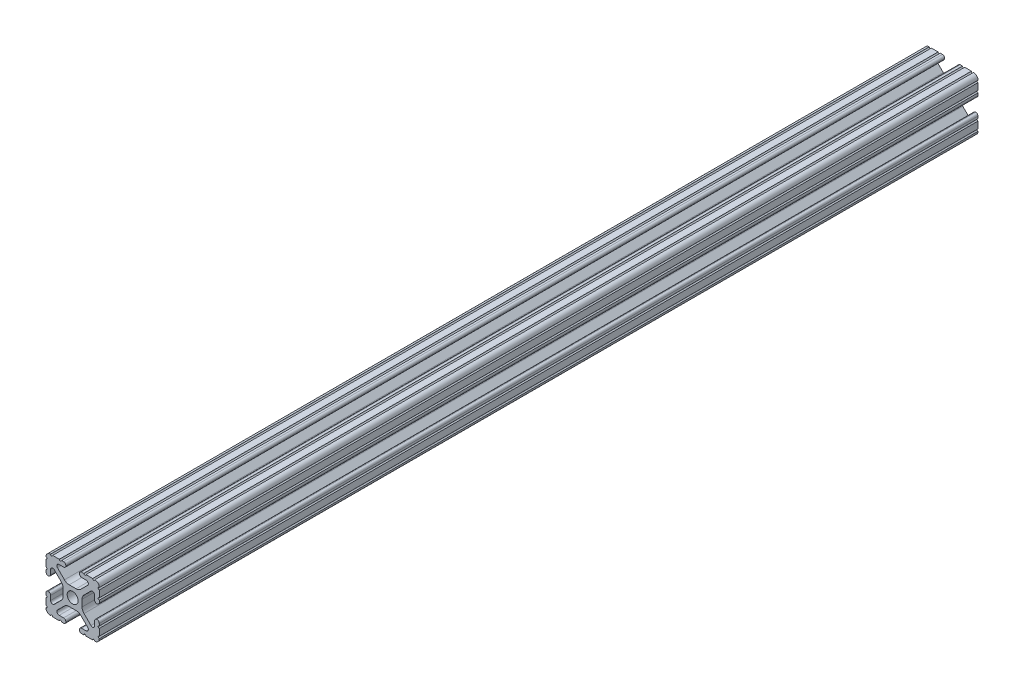
from build123d import *

# Parameters (mm, degrees)
SKETCH1_R           = 2.6035
BOSS_EXTRUDE1_DEPTH = 209.55


with BuildPart() as part:
    # Sketch1 → Boss-Extrude1 (new body, symmetric)
    with BuildSketch(Plane.XY):
        with BuildLine():
            Line((-7.179650497, -8.645192506), (-3.952270251, -5.423690499))
            ThreePointArc((-3.952270251, -5.423690499), (-2.922936451, -4.736929036), (-1.709253557, -4.4958))
            Line((-1.709253557, -4.4958), (1.709253557, -4.4958))
            ThreePointArc((1.709253557, -4.4958), (2.922936451, -4.736929036), (3.952270251, -5.423690499))
            Line((3.952270251, -5.423690499), (7.179650497, -8.645192506))
            ThreePointArc((7.179650497, -8.645192506), (7.41473083, -9.822813117), (6.416408329, -10.4902))
            Line((6.416408329, -10.4902), (4.287512407, -10.4902))
            ThreePointArc((4.287512407, -10.4902), (3.54574862, -10.79744862), (3.2385, -11.539212407))
            Line((3.2385, -11.539212407), (3.2385, -11.650987593))
            ThreePointArc((3.2385, -11.650987593), (3.54574862, -12.39275138), (4.287512407, -12.7))
            Line((4.287512407, -12.7), (5.317126718, -12.7))
            ThreePointArc((5.317126718, -12.7), (5.825126718, -12.192), (6.333126718, -12.7))
            Line((6.333126718, -12.7), (9.550443118, -12.7))
            ThreePointArc((9.550443118, -12.7), (10.058366869, -12.192000006), (10.566443095, -12.699847501))
            ThreePointArc((10.566443095, -12.699847501), (12.082537762, -12.08250727), (12.699846982, -10.566399977))
            ThreePointArc((12.699846982, -10.566399977), (12.192000006, -10.058323491), (12.7, -9.5504))
            Line((12.7, -9.5504), (12.7, -6.3330836))
            ThreePointArc((12.7, -6.3330836), (12.192, -5.8250836), (12.7, -5.3170836))
            Line((12.7, -5.3170836), (12.7, -4.287469289))
            ThreePointArc((12.7, -4.287469289), (12.39275138, -3.545705502), (11.650987593, -3.238456882))
            Line((11.650987593, -3.238456882), (11.539212407, -3.238456882))
            ThreePointArc((11.539212407, -3.238456882), (10.79744862, -3.545705502), (10.4902, -4.287469289))
            Line((10.4902, -4.287469289), (10.4902, -6.402089023))
            ThreePointArc((10.4902, -6.402089023), (9.856505071, -7.351067942), (8.737131347, -7.129408934))
            Line((8.737131347, -7.129408934), (5.441005833, -3.840816462))
            ThreePointArc((5.441005833, -3.840816462), (4.750877967, -2.809883091), (4.5085, -1.593185507))
            Line((4.5085, -1.593185507), (4.5085, 1.593185507))
            ThreePointArc((4.5085, 1.593185507), (4.750877967, 2.809883091), (5.441005833, 3.840816462))
            Line((5.441005833, 3.840816462), (8.737131347, 7.129408934))
            ThreePointArc((8.737131347, 7.129408934), (9.856505071, 7.351067942), (10.4902, 6.402089023))
            Line((10.4902, 6.402089023), (10.4902, 4.287469289))
            ThreePointArc((10.4902, 4.287469289), (10.79744862, 3.545705502), (11.539212407, 3.238456882))
            Line((11.539212407, 3.238456882), (11.650987593, 3.238456882))
            ThreePointArc((11.650987593, 3.238456882), (12.39275138, 3.545705502), (12.7, 4.287469289))
            Line((12.7, 4.287469289), (12.7, 5.3170836))
            ThreePointArc((12.7, 5.3170836), (12.192, 5.8250836), (12.7, 6.3330836))
            Line((12.7, 6.3330836), (12.7, 9.5504))
            ThreePointArc((12.7, 9.5504), (12.192000006, 10.058323491), (12.699846982, 10.566399977))
            ThreePointArc((12.699846982, 10.566399977), (12.082537762, 12.08250727), (10.566443095, 12.699847501))
            ThreePointArc((10.566443095, 12.699847501), (10.058366869, 12.192000006), (9.550443118, 12.7))
            Line((9.550443118, 12.7), (6.333126718, 12.7))
            ThreePointArc((6.333126718, 12.7), (5.825126718, 12.192), (5.317126718, 12.7))
            Line((5.317126718, 12.7), (4.287512407, 12.7))
            ThreePointArc((4.287512407, 12.7), (3.54574862, 12.39275138), (3.2385, 11.650987593))
            Line((3.2385, 11.650987593), (3.2385, 11.539212407))
            ThreePointArc((3.2385, 11.539212407), (3.54574862, 10.79744862), (4.287512407, 10.4902))
            Line((4.287512407, 10.4902), (6.476788598, 10.4902))
            ThreePointArc((6.476788598, 10.4902), (7.432222385, 9.85140422), (7.207036008, 8.724370562))
            Line((7.207036008, 8.724370562), (3.898272566, 5.423169045))
            ThreePointArc((3.898272566, 5.423169045), (2.869120213, 4.736787962), (1.655778399, 4.4958))
            Line((1.655778399, 4.4958), (-1.655778399, 4.4958))
            ThreePointArc((-1.655778399, 4.4958), (-2.869120213, 4.736787962), (-3.898272566, 5.423169045))
            Line((-3.898272566, 5.423169045), (-7.207036008, 8.724370562))
            ThreePointArc((-7.207036008, 8.724370562), (-7.432222385, 9.85140422), (-6.476788598, 10.4902))
            Line((-6.476788598, 10.4902), (-4.287512407, 10.4902))
            ThreePointArc((-4.287512407, 10.4902), (-3.54574862, 10.79744862), (-3.2385, 11.539212407))
            Line((-3.2385, 11.539212407), (-3.2385, 11.650987593))
            ThreePointArc((-3.2385, 11.650987593), (-3.54574862, 12.39275138), (-4.287512407, 12.7))
            Line((-4.287512407, 12.7), (-5.317126718, 12.7))
            ThreePointArc((-5.317126718, 12.7), (-5.825126718, 12.192), (-6.333126718, 12.7))
            Line((-6.333126718, 12.7), (-9.550443118, 12.7))
            ThreePointArc((-9.550443118, 12.7), (-10.058366869, 12.192000006), (-10.566443095, 12.699847501))
            ThreePointArc((-10.566443095, 12.699847501), (-12.082537762, 12.08250727), (-12.699846982, 10.566399977))
            ThreePointArc((-12.699846982, 10.566399977), (-12.192000006, 10.058323491), (-12.7, 9.5504))
            Line((-12.7, 9.5504), (-12.7, 6.3330836))
            ThreePointArc((-12.7, 6.3330836), (-12.192, 5.8250836), (-12.7, 5.3170836))
            Line((-12.7, 5.3170836), (-12.7, 4.287469289))
            ThreePointArc((-12.7, 4.287469289), (-12.39275138, 3.545705502), (-11.650987593, 3.238456882))
            Line((-11.650987593, 3.238456882), (-11.539212407, 3.238456882))
            ThreePointArc((-11.539212407, 3.238456882), (-10.79744862, 3.545705502), (-10.4902, 4.287469289))
            Line((-10.4902, 4.287469289), (-10.4902, 6.402089023))
            ThreePointArc((-10.4902, 6.402089023), (-9.856505071, 7.351067942), (-8.737131347, 7.129408934))
            Line((-8.737131347, 7.129408934), (-5.441005833, 3.840816462))
            ThreePointArc((-5.441005833, 3.840816462), (-4.750877967, 2.809883091), (-4.5085, 1.593185507))
            Line((-4.5085, 1.593185507), (-4.5085, -1.593185507))
            ThreePointArc((-4.5085, -1.593185507), (-4.750877967, -2.809883091), (-5.441005833, -3.840816462))
            Line((-5.441005833, -3.840816462), (-8.737131347, -7.129408934))
            ThreePointArc((-8.737131347, -7.129408934), (-9.856505071, -7.351067942), (-10.4902, -6.402089023))
            Line((-10.4902, -6.402089023), (-10.4902, -4.287469289))
            ThreePointArc((-10.4902, -4.287469289), (-10.79744862, -3.545705502), (-11.539212407, -3.238456882))
            Line((-11.539212407, -3.238456882), (-11.650987593, -3.238456882))
            ThreePointArc((-11.650987593, -3.238456882), (-12.39275138, -3.545705502), (-12.7, -4.287469289))
            Line((-12.7, -4.287469289), (-12.7, -5.3170836))
            ThreePointArc((-12.7, -5.3170836), (-12.192, -5.8250836), (-12.7, -6.3330836))
            Line((-12.7, -6.3330836), (-12.7, -9.5504))
            ThreePointArc((-12.7, -9.5504), (-12.192000006, -10.058323491), (-12.699846982, -10.566399977))
            ThreePointArc((-12.699846982, -10.566399977), (-12.082537762, -12.08250727), (-10.566443095, -12.699847501))
            ThreePointArc((-10.566443095, -12.699847501), (-10.058366869, -12.192000006), (-9.550443118, -12.7))
            Line((-9.550443118, -12.7), (-6.333126718, -12.7))
            ThreePointArc((-6.333126718, -12.7), (-5.825126718, -12.192), (-5.317126718, -12.7))
            Line((-5.317126718, -12.7), (-4.287512407, -12.7))
            ThreePointArc((-4.287512407, -12.7), (-3.54574862, -12.39275138), (-3.2385, -11.650987593))
            Line((-3.2385, -11.650987593), (-3.2385, -11.539212407))
            ThreePointArc((-3.2385, -11.539212407), (-3.54574862, -10.79744862), (-4.287512407, -10.4902))
            Line((-4.287512407, -10.4902), (-6.416408329, -10.4902))
            ThreePointArc((-6.416408329, -10.4902), (-7.41473083, -9.822813117), (-7.179650497, -8.645192506))
        make_face()
        Circle(SKETCH1_R, mode=Mode.SUBTRACT)
    extrude(amount=BOSS_EXTRUDE1_DEPTH, both=True)


solid = part.part
